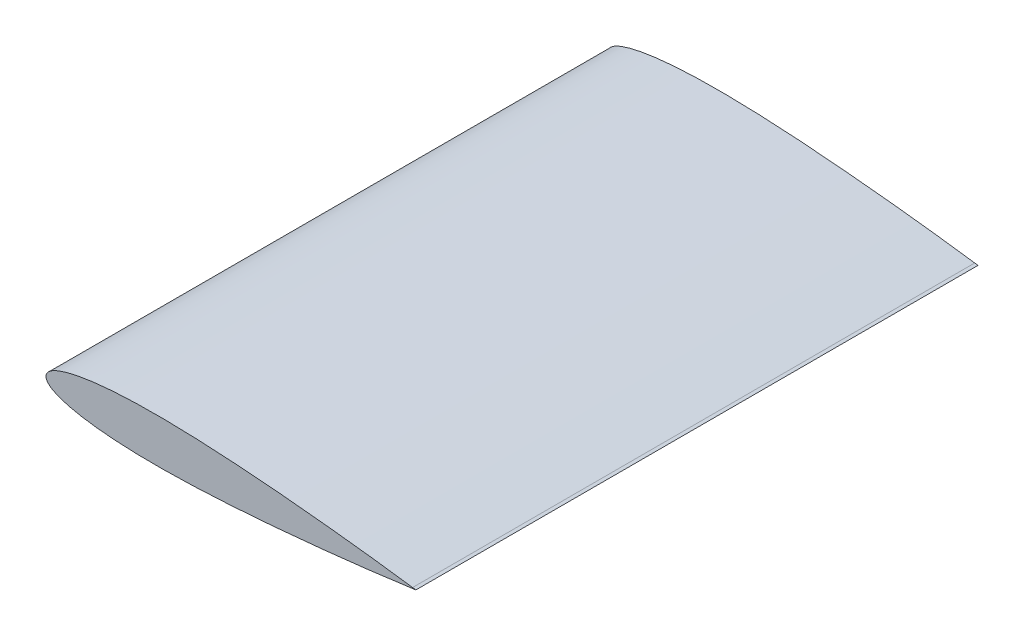
from build123d import *

# Parameters (mm, degrees)
BOSS_EXTRUDE2_DEPTH = 115


with BuildPart() as part:
    # Sketch3 → Boss-Extrude2 (new body, symmetric)
    with BuildSketch(Plane.XY):
        with BuildLine():
            Line((150, 0.189), (151.347229645, 0))
            Line((151.347229645, 0), (150, -0.189))
            add(Edge.make_bspline(
                [(150, 0.189), (149.970805097, 0.193095691), (149.854098258, 0.209468247), (149.591763349, 0.246194704), (149.155222793, 0.307178536), (148.545492513, 0.39195557), (147.763997301, 0.500005904), (146.812564376, 0.630620596), (145.693410705, 0.782990201), (144.409151468, 0.956135403), (142.96278679, 1.149035599), (141.357691781, 1.360477155), (139.597619337, 1.589324284), (137.686668602, 1.834170852), (135.629312335, 2.093761294), (133.430351174, 2.366642532), (131.094926884, 2.651439142), (128.628484118, 2.946658173), (126.036790348, 3.250845027), (123.325898879, 3.56250519), (120.502146425, 3.880189358), (117.572116772, 4.202283272), (113.473476188, 4.642066436), (109.256000086, 5.07708862), (104.929525823, 5.504434772), (101.575177437, 5.825363227), (98.158766856, 6.14116737), (94.688264753, 6.450074981), (91.171786603, 6.750309754), (87.617532174, 7.040052014), (84.033808187, 7.317409054), (80.428982039, 7.580524939), (76.81147399, 7.827427414), (73.189728326, 8.056177938), (69.572203149, 8.264831419), (65.967345764, 8.451449418), (62.383569552, 8.61415188), (58.82924139, 8.751092101), (55.312663472, 8.860508291), (51.842049335, 8.940802336), (48.425495498, 8.990447931), (45.070979504, 9.008099882), (41.786333894, 8.992603847), (38.579230275, 8.943033204), (35.457151092, 8.858620583), (32.42738238, 8.73890472), (29.496997903, 8.583661815), (26.67283973, 8.392857183), (23.961487045, 8.166811178), (21.369257604, 7.906046678), (18.902195955, 7.611289257), (16.56603561, 7.28359179), (14.36621034, 6.924060565), (12.307797254, 6.534171091), (10.395554823, 6.115341941), (8.633834596, 5.669293664), (7.026635576, 5.197645541), (5.577494925, 4.702174511), (4.289505643, 4.184540505), (3.165222949, 3.646284269), (2.206640217, 3.088625915), (1.415160343, 2.512199049), (0.791935763, 1.916452918), (0.338982961, 1.299295019), (0.061800404, 0.658046728), (-0.030125986, 0), (0.061800404, -0.658046728), (0.338982961, -1.299295019), (0.791935763, -1.916452918), (1.415160343, -2.512199049), (2.206640217, -3.088625915), (3.165222949, -3.646284269), (4.289505643, -4.184540505), (5.577494925, -4.702174511), (7.026635576, -5.197645541), (8.633834596, -5.669293664), (10.395554823, -6.115341941), (12.307797254, -6.534171091), (14.36621034, -6.924060565), (16.56603561, -7.28359179), (18.902195955, -7.611289257), (21.369257604, -7.906046678), (23.961487045, -8.166811178), (26.67283973, -8.392857183), (29.496997903, -8.583661815), (32.42738238, -8.73890472), (35.457151092, -8.858620583), (38.579230275, -8.943033204), (41.786333894, -8.992603847), (45.070979504, -9.008099882), (48.425495498, -8.990447931), (51.842049335, -8.940802336), (55.312663472, -8.860508291), (58.82924139, -8.751092101), (62.383569552, -8.61415188), (65.967345764, -8.451449418), (69.572203149, -8.264831419), (73.189728326, -8.056177938), (76.81147399, -7.827427414), (80.428982039, -7.580524939), (84.033808187, -7.317409054), (87.617532174, -7.040052014), (91.171786603, -6.750309754), (94.688264753, -6.450074981), (98.158766856, -6.14116737), (102.671510989, -5.724020994), (108.137829774, -5.192427185), (113.473476188, -4.642066436), (117.572116772, -4.202283272), (120.502146425, -3.880189358), (123.325898879, -3.56250519), (126.036790348, -3.250845027), (128.628484118, -2.946658173), (131.094926884, -2.651439142), (133.430351174, -2.366642532), (135.629312335, -2.093761294), (137.686668602, -1.834170852), (139.597619337, -1.589324284), (141.357691781, -1.360477155), (142.96278679, -1.149035599), (144.409151468, -0.956135403), (145.693410705, -0.782990201), (146.812564376, -0.630620596), (147.763997301, -0.500005904), (148.545492513, -0.39195557), (149.155222793, -0.307178536), (149.591763349, -0.246194704), (149.854098258, -0.209468247), (149.970805097, -0.193095691), (150, -0.189)],
                knots=[0, 0, 0, 0, 0.000289146, 0.001155863, 0.002598059, 0.004612289, 0.007193593, 0.010335835, 0.014031413, 0.018271453, 0.023045738, 0.028342882, 0.034150137, 0.040453731, 0.047238593, 0.054488555, 0.062186438, 0.070313976, 0.078851943, 0.087780092, 0.097077362, 0.106721847, 0.116690748, 0.137507311, 0.148305913, 0.15933101, 0.170556758, 0.181956676, 0.19350401, 0.205171586, 0.216932159, 0.228757987, 0.24062146, 0.252494886, 0.264350491, 0.276160731, 0.287898257, 0.299535925, 0.311046959, 0.322405016, 0.333584241, 0.344559427, 0.355305877, 0.365799652, 0.376017633, 0.385937515, 0.395537821, 0.404798054, 0.413698797, 0.422221689, 0.430349461, 0.438066152, 0.445357166, 0.452209423, 0.458611485, 0.464554009, 0.470029938, 0.475035084, 0.479569179, 0.483636916, 0.487250222, 0.490431493, 0.493218847, 0.49567407, 0.497891229, 0.5, 0.502108771, 0.50432593, 0.506781153, 0.509568507, 0.512749778, 0.516363084, 0.520430821, 0.524964916, 0.529970062, 0.535445991, 0.541388515, 0.547790577, 0.554642834, 0.561933848, 0.569650539, 0.577778311, 0.586301203, 0.595201946, 0.604462179, 0.614062485, 0.623982367, 0.634200348, 0.644694123, 0.655440573, 0.666415759, 0.677594984, 0.688953041, 0.700464075, 0.712101743, 0.723839269, 0.735649509, 0.747505114, 0.75937854, 0.771242013, 0.783067841, 0.794828414, 0.80649599, 0.818043324, 0.829443242, 0.84066899, 0.862492689, 0.883309252, 0.893278153, 0.902922638, 0.912219908, 0.921148057, 0.929686024, 0.937813562, 0.945511445, 0.952761407, 0.959546269, 0.965849863, 0.971657118, 0.976954262, 0.981728547, 0.985968587, 0.989664165, 0.992806407, 0.995387711, 0.997401941, 0.998844137, 0.999710854, 1, 1, 1, 1], degree=3))
        make_face()
    extrude(amount=BOSS_EXTRUDE2_DEPTH, both=True)


solid = part.part
